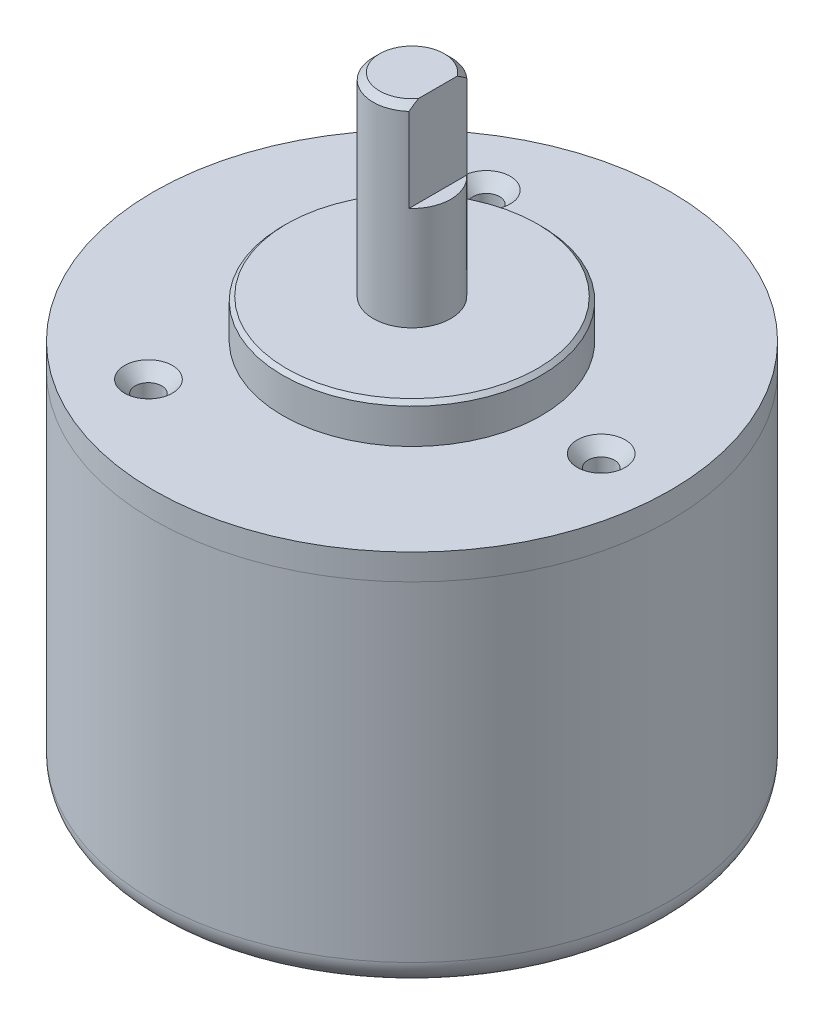
from build123d import *

# Parameters (mm, degrees)
CROQUIS1_R              = 20
SALIENTE_EXTRUIR1_DEPTH = 2
CROQUIS2_R              = 10
SALIENTE_EXTRUIR2_DEPTH = 3
CROQUIS3_R              = 3
SALIENTE_EXTRUIR3_DEPTH = 15
CHAFL_N1_SIZE           = 0.5
CHAFL_N2_SIZE           = 0.3
CROQUIS4_R              = 20
SALIENTE_EXTRUIR4_DEPTH = 27.5
REDONDEO1_R             = 2
CORTAR_EXTRUIR2_DEPTH   = 7
MATRIZC8_COUNT          = 3


with BuildPart() as part:
    # Croquis1 → Saliente-Extruir1 (new body)
    with BuildSketch(Plane(origin=(0, 0, 0), x_dir=(1, 0, 0), z_dir=(0, 1, 0))):
        Circle(CROQUIS1_R)
    extrude(amount=SALIENTE_EXTRUIR1_DEPTH)

    # Croquis2 → Saliente-Extruir2 (add)
    with BuildSketch(Plane(origin=(0, 2, 0), x_dir=(1, 0, 0), z_dir=(0, 1, 0))):
        Circle(CROQUIS2_R)
    extrude(amount=SALIENTE_EXTRUIR2_DEPTH)

    # Croquis3 → Saliente-Extruir3 (add)
    with BuildSketch(Plane(origin=(0, 5, 0), x_dir=(1, 0, 0), z_dir=(0, 1, 0))):
        Circle(CROQUIS3_R)
    extrude(amount=SALIENTE_EXTRUIR3_DEPTH)

    # Chaflán1
    chafl_n1_edges = [part.edges().sort_by_distance(p)[0] for p in [
        (-3, 20, 0),
    ]]
    chamfer(chafl_n1_edges, length=CHAFL_N1_SIZE)

    # Chaflán2
    chafl_n2_edges = [part.edges().sort_by_distance(p)[0] for p in [
        (-10, 5, 0),
    ]]
    chamfer(chafl_n2_edges, length=CHAFL_N2_SIZE)

    # Croquis6 → Cortar-Extruir2 (cut)
    with BuildSketch(Plane(origin=(0, 20, 0), x_dir=(1, 0, 0), z_dir=(0, 1, 0))):
        Polygon((2, 0), (2, -3), (4, -3), (4, 3), (2, 3), align=None)
    extrude(amount=-CORTAR_EXTRUIR2_DEPTH, mode=Mode.SUBTRACT)


with BuildPart() as body_2:
    # Croquis4 → Saliente-Extruir4 (new body)
    with BuildSketch(Plane.XZ):
        Circle(CROQUIS4_R)
    extrude(amount=SALIENTE_EXTRUIR4_DEPTH)

    # Redondeo1
    redondeo1_edges = [body_2.edges().sort_by_distance(p)[0] for p in [
        (-20, -27.5, 0),
    ]]
    fillet(redondeo1_edges, radius=REDONDEO1_R)


with BuildPart() as avellanado_para_tornillo_con_cabeza_oval_tool:
    # Croquis9 → Avellanado para tornillo con cabeza ovalada de #11 (revolve)
    with BuildSketch(Plane(origin=(14.86435082, 2, 0.225997135), x_dir=(0, 0, 1), z_dir=(1, 0, 0))):
        Polygon((0, 0), (0, 10.618105319), (1.0287, 10), (1.0287, 0.94962912), (1.8542, 0), align=None)
    avellanado_para_tornillo_con_cabeza_oval = revolve(axis=Axis((14.86435082, 8.35, 0.225997135), (0, -1, 0)))


with BuildPart() as part_1:
    add(part.part)

    # Avellanado para tornillo con cabeza ovalada de #11: cut by avellanado_para_tornillo_con_cabeza_oval_tool
    add(avellanado_para_tornillo_con_cabeza_oval_tool.part, mode=Mode.SUBTRACT)


with BuildPart() as body_2_1:
    add(body_2.part)

    # Avellanado para tornillo con cabeza ovalada de #11: cut by avellanado_para_tornillo_con_cabeza_oval_tool
    add(avellanado_para_tornillo_con_cabeza_oval_tool.part, mode=Mode.SUBTRACT)


with BuildPart() as matrizc8_tool:
    # MatrizC8: Avellanado para tornillo con cabeza ovalada de #11 ×3 about axis
    matrizc8_axis = Axis((0, 0, 0), (0, 1, 0))
    for i in range(1, MATRIZC8_COUNT):
        add(avellanado_para_tornillo_con_cabeza_oval.rotate(matrizc8_axis, i * 360 / MATRIZC8_COUNT))


with BuildPart() as part_2:
    add(part_1.part)

    # MatrizC8: cut by matrizc8_tool
    add(matrizc8_tool.part, mode=Mode.SUBTRACT)


with BuildPart() as body_2_2:
    add(body_2_1.part)

    # MatrizC8: cut by matrizc8_tool
    add(matrizc8_tool.part, mode=Mode.SUBTRACT)


solid = Compound([part_2.part, body_2_2.part])
